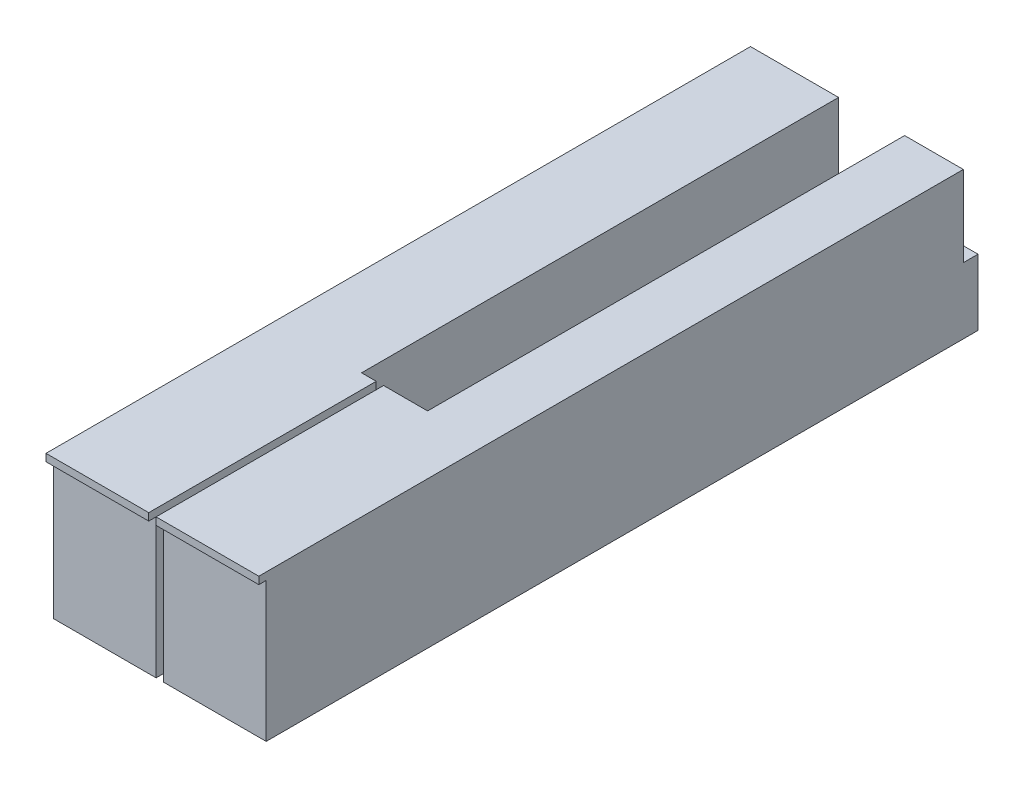
from build123d import *

# Parameters (mm, degrees)
BOSS_EXTRUDE1_DEPTH   = 31.75
BOSS_EXTRUDE1_2_DEPTH = 31.75
SKETCH2_W             = 1.5875
SKETCH2_H             = 30.1625
CUT_EXTRUDE1_DEPTH    = 47.0375
SKETCH3_W             = 3.175
SKETCH3_H             = 14.2875
BOSS_EXTRUDE2_DEPTH   = 46.0375


with BuildPart() as part:
    # Sketch1 → Boss-Extrude1 (new body)
    with BuildSketch(Plane(origin=(0, 0, 0), x_dir=(1, 0, 0), z_dir=(0, 1, 0))):
        Polygon((0, 0), (0, 152.4), (-12.7, 152.4), (-12.7, 49.2125), (-22.225, 49.2125), (-22.225, 0), align=None)
    extrude(amount=BOSS_EXTRUDE1_DEPTH)


with BuildPart() as body_2:
    # Sketch1 → Boss-Extrude1 2 (new body)
    with BuildSketch(Plane(origin=(0, 0, 0), x_dir=(1, 0, 0), z_dir=(0, 1, 0))):
        Polygon((-23.8125, 0), (-46.0375, 0), (-46.0375, 152.4), (-26.9875, 152.4), (-26.9875, 49.2125), (-23.8125, 49.2125), align=None)
    extrude(amount=BOSS_EXTRUDE1_2_DEPTH)


with BuildPart() as cut_extrude1_tool:
    # Sketch2 → Cut-Extrude1 (new body, through all)
    with BuildSketch(Plane(origin=(0, 0, 0), x_dir=(0, 0, -1), z_dir=(1, 0, 0))):
        with Locations((0.79375, 15.08125)):
            Rectangle(SKETCH2_W, SKETCH2_H)
    extrude(amount=-CUT_EXTRUDE1_DEPTH)


with BuildPart() as part_1:
    add(part.part)

    # Cut-Extrude1: cut by cut_extrude1_tool
    add(cut_extrude1_tool.part, mode=Mode.SUBTRACT)



with BuildPart() as body_2_1:
    add(body_2.part)

    # Cut-Extrude1: cut by cut_extrude1_tool
    add(cut_extrude1_tool.part, mode=Mode.SUBTRACT)


with BuildPart() as part_2:
    add(part_1.part)

    add(body_2_1.part)  # Boss-Extrude2 merges body 2
    # Sketch3 → Boss-Extrude2 (add)
    with BuildSketch(Plane(origin=(0, 0, 0), x_dir=(0, 0, -1), z_dir=(1, 0, 0))):
        with Locations((153.9875, 7.14375)):
            Rectangle(SKETCH3_W, SKETCH3_H)
    extrude(amount=-BOSS_EXTRUDE2_DEPTH)


solid = part_2.part
